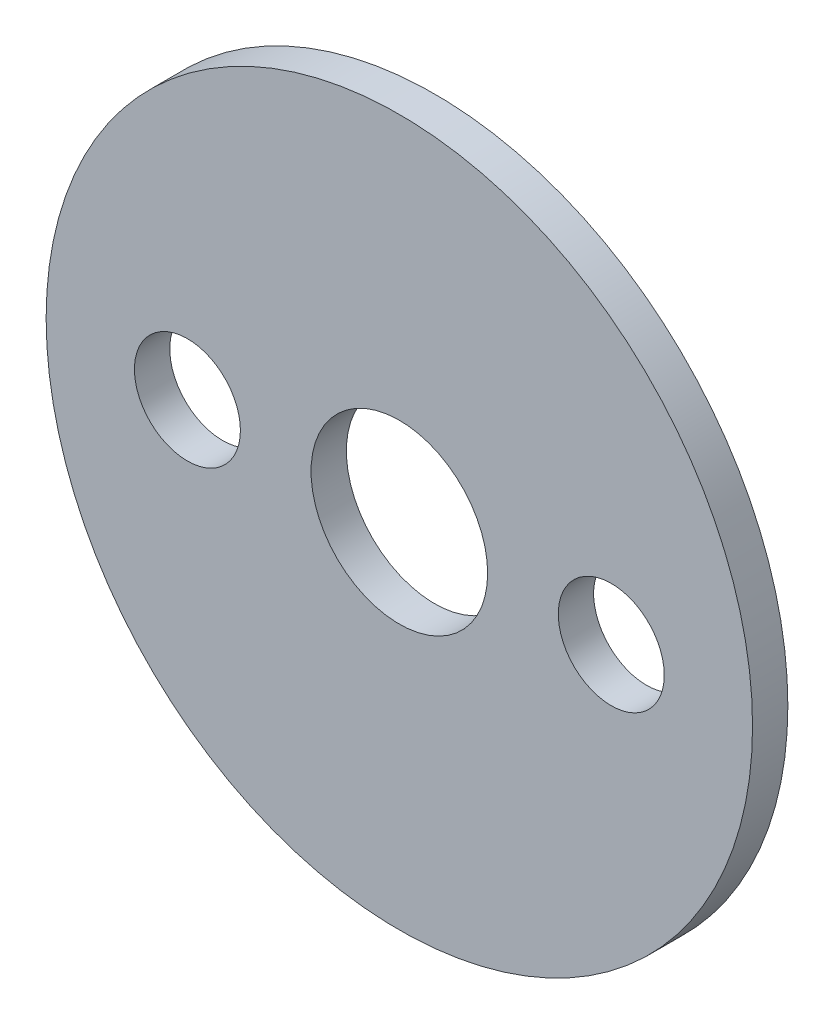
from build123d import *

# Parameters (mm, degrees)
CROQUIS1_R                 = 2.5
CROQUIS1_R_2               = 0.625
SALIENTE_EXTRUIR1_DEPTH    = 0.25
TALADRO_ROSCADO_M1X0_251_D = 0.75


with BuildPart() as part:
    # Croquis1 → Saliente-Extruir1 (new body)
    with BuildSketch(Plane.XY):
        Circle(CROQUIS1_R)
        Circle(CROQUIS1_R_2, mode=Mode.SUBTRACT)
    extrude(amount=SALIENTE_EXTRUIR1_DEPTH)

    # Taladro roscado M1x0.251 (through all)
    with Locations(Plane.XY.offset(0.25)):
        with Locations((-1.5, 0), (1.5, 0)):
            Hole(TALADRO_ROSCADO_M1X0_251_D / 2)


solid = part.part
